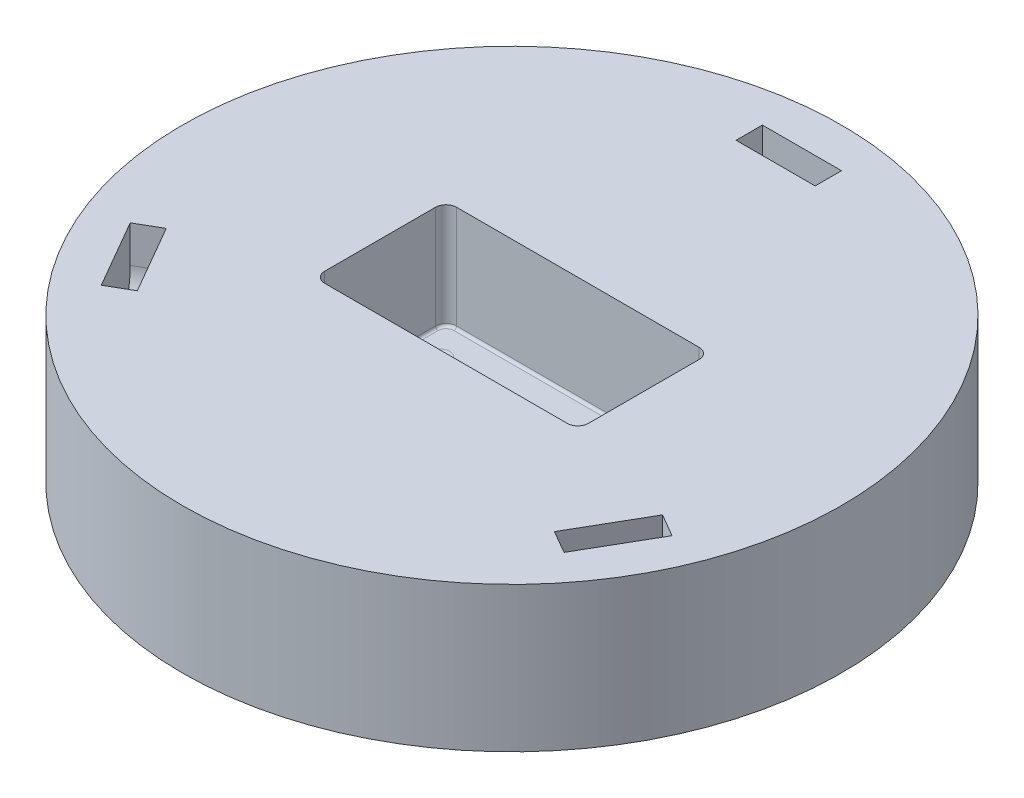
from build123d import *

# Parameters (mm, degrees)
SKETCH1_R                     = 79.375
BOSS_EXTRUDE1_DEPTH           = 17.4625
SKETCH3_W                     = 63.5
SKETCH3_H                     = 31.75
CUT_EXTRUDE1_DEPTH            = 25.4
CBORE_FOR_M3_SHCS1_AT_2_COUNT = 2
CBORE_FOR_M3_SHCS1_AT_2_PITCH = 53.2226984
CBORE_FOR_M3_SHCS1_AT_3_COUNT = 2
CBORE_FOR_M3_SHCS1_AT_3_PITCH = 15.875
CBORE_FOR_M3_SHCS1_AT_4_COUNT = 2
CBORE_FOR_M3_SHCS1_AT_4_PITCH = 50.8
FILLET1_R                     = 2.54
FILLET2_R                     = 0.635
CUT_EXTRUDE2_DEPTH            = 3.175
CIRPATTERN1_COUNT             = 3
SKETCH9_R                     = 2.75
CUT_EXTRUDE3_DEPTH            = 8


with BuildPart() as part:
    # Sketch1 → Boss-Extrude1 (new body, symmetric)
    with BuildSketch(Plane(origin=(1517.792794823, 0, 847.495824357), x_dir=(0.865443398, 0, 0.501006711), z_dir=(0, 1, 0))):
        with Locations((-337.334966363, -781.702362363)):
            Circle(SKETCH1_R)
    extrude(amount=BOSS_EXTRUDE1_DEPTH, both=True)

    # Sketch3 → Cut-Extrude1 (cut)
    with BuildSketch(Plane(origin=(0, 17.4625, 0), x_dir=(1, 0, 0), z_dir=(0, 1, 0))):
        with Locations((834.21034581, -1355.007891462)):
            Rectangle(SKETCH3_W, SKETCH3_H)
    extrude(amount=-CUT_EXTRUDE1_DEPTH, mode=Mode.SUBTRACT)

    # Sketch7 → CBORE for M3 SHCS1 (revolve, cut)
    with BuildSketch(Plane(origin=(859.61034581, -17.4625, 1362.945391462), x_dir=(0, 0, -1), z_dir=(1, 0, 0))):
        Polygon((0, 0), (0, 34.925), (1.8, 34.925), (1.8, 3), (3.25, 3), (3.25, 0.025), (3.275, 0), align=None)
    cbore_for_m3_shcs1 = revolve(axis=Axis((859.61034581, -23.8125, 1362.945391462), (0, 1, 0)), mode=Mode.SUBTRACT)

    # CBORE for M3 SHCS1 at 2: CBORE for M3 SHCS1 ×2
    with Locations(*[Vector(-0.954479978, 0, -0.298274993) * (i * CBORE_FOR_M3_SHCS1_AT_2_PITCH) for i in range(1, CBORE_FOR_M3_SHCS1_AT_2_COUNT)]):
        add(cbore_for_m3_shcs1, mode=Mode.SUBTRACT)

    # CBORE for M3 SHCS1 at 3: CBORE for M3 SHCS1 ×2
    with Locations(*[(0, 0, -i * CBORE_FOR_M3_SHCS1_AT_3_PITCH) for i in range(1, CBORE_FOR_M3_SHCS1_AT_3_COUNT)]):
        add(cbore_for_m3_shcs1, mode=Mode.SUBTRACT)

    # CBORE for M3 SHCS1 at 4: CBORE for M3 SHCS1 ×2
    with Locations(*[(-i * CBORE_FOR_M3_SHCS1_AT_4_PITCH, 0, 0) for i in range(1, CBORE_FOR_M3_SHCS1_AT_4_COUNT)]):
        add(cbore_for_m3_shcs1, mode=Mode.SUBTRACT)

    # Fillet1
    fillet1_edges = [part.edges().sort_by_distance(p)[0] for p in [
        (802.46034581, 4.7625, 1370.882891462),
        (802.46034581, 4.7625, 1339.132891462),
        (865.96034581, 4.7625, 1339.132891462),
        (865.96034581, 4.7625, 1370.882891462),
    ]]
    fillet(fillet1_edges, radius=FILLET1_R)

    # Fillet2
    fillet2_edges = [part.edges().sort_by_distance(p)[0] for p in [
        (808.81034581, -7.9375, 1364.745391462),
        (859.61034581, -7.9375, 1348.870391462),
        (859.61034581, -7.9375, 1364.745391462),
        (808.81034581, -7.9375, 1348.870391462),
        (802.46034581, -7.9375, 1355.007891462),
        (834.21034581, -7.9375, 1339.132891462),
        (834.21034581, -7.9375, 1370.882891462),
        (865.96034581, -7.9375, 1355.007891462),
        (865.216397034, -7.9375, 1339.876840238),
        (865.216397034, -7.9375, 1370.138942686),
        (803.204294586, -7.9375, 1370.138942686),
        (803.204294586, -7.9375, 1339.876840238),
    ]]
    fillet(fillet2_edges, radius=FILLET2_R)

    # Sketch8 → Cut-Extrude2 (cut, symmetric)
    with BuildSketch(Plane.XY.offset(1288.332891462)):
        with BuildLine():
            Line((843.73534581, 8.5725), (843.73534581, 17.4625))
            Line((843.73534581, 17.4625), (824.68534581, 17.4625))
            Line((824.68534581, 17.4625), (824.68534581, 8.5725))
            ThreePointArc((824.68534581, 8.5725), (834.21034581, -0.9525), (843.73534581, 8.5725))
        make_face()
    cut_extrude2 = extrude(amount=CUT_EXTRUDE2_DEPTH, both=True, mode=Mode.SUBTRACT)

    # CirPattern1: Cut-Extrude2 ×3 about axis
    cirpattern1_axis = Axis((834.21034581, 0, 1355.007891462), (0, 1, 0))
    for i in range(1, CIRPATTERN1_COUNT):
        add(cut_extrude2.rotate(cirpattern1_axis, i * 360 / CIRPATTERN1_COUNT), mode=Mode.SUBTRACT)

    # Sketch9 → Cut-Extrude3 (cut)
    with BuildSketch(Plane.XZ.offset(17.4625)):
        with Locations((881.83534581, 1307.382891462)):
            Circle(SKETCH9_R)
        with Locations((786.58534581, 1307.382891462)):
            Circle(SKETCH9_R)
        with Locations((786.58534581, 1402.632891462)):
            Circle(SKETCH9_R)
        with Locations((881.83534581, 1402.632891462)):
            Circle(SKETCH9_R)
    extrude(amount=-CUT_EXTRUDE3_DEPTH, mode=Mode.SUBTRACT)


solid = part.part
